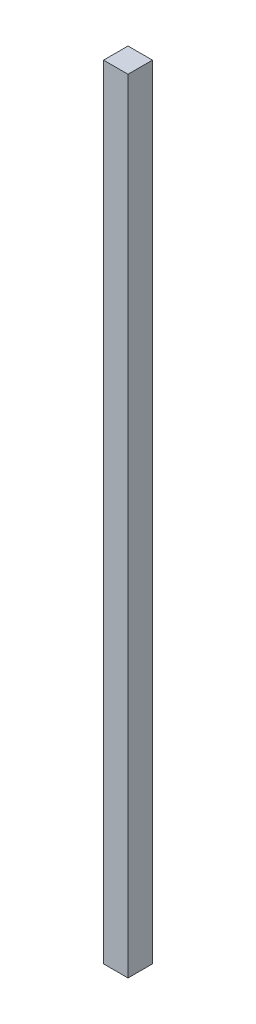
from build123d import *

# Parameters (mm, degrees)
SKETCH1_W           = 6.35
SKETCH1_H           = 6.35
BOSS_EXTRUDE1_DEPTH = 203.2


with BuildPart() as part:
    # Sketch1 → Boss-Extrude1 (new body)
    with BuildSketch(Plane(origin=(0, 0, 0), x_dir=(1, 0, 0), z_dir=(0, 1, 0))):
        Rectangle(SKETCH1_W, SKETCH1_H)
    extrude(amount=BOSS_EXTRUDE1_DEPTH)


solid = part.part
